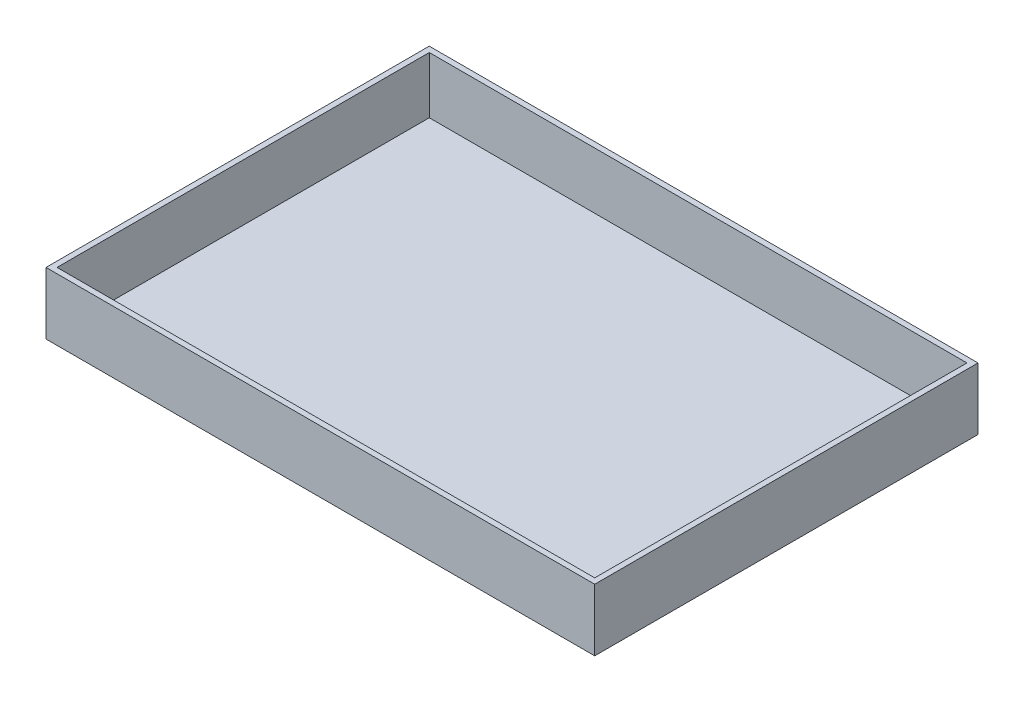
from build123d import *

# Parameters (mm, degrees)
SKETCH1_W           = 252.73
SKETCH1_H           = 176.53
BOSS_EXTRUDE1_DEPTH = 28.575
SHELL1_T            = -2.54


with BuildPart() as part:
    # Sketch1 → Boss-Extrude1 (new body)
    with BuildSketch(Plane(origin=(0, 0, 0), x_dir=(1, 0, 0), z_dir=(0, 1, 0))):
        with Locations((126.365, -88.265)):
            Rectangle(SKETCH1_W, SKETCH1_H)
    extrude(amount=BOSS_EXTRUDE1_DEPTH)

    # Shell1
    shell1_openings = [part.faces().sort_by_distance(p)[0] for p in [
        (126.365, 28.575, 88.265),
    ]]
    offset(amount=SHELL1_T, openings=shell1_openings, kind=Kind.INTERSECTION)


solid = part.part
